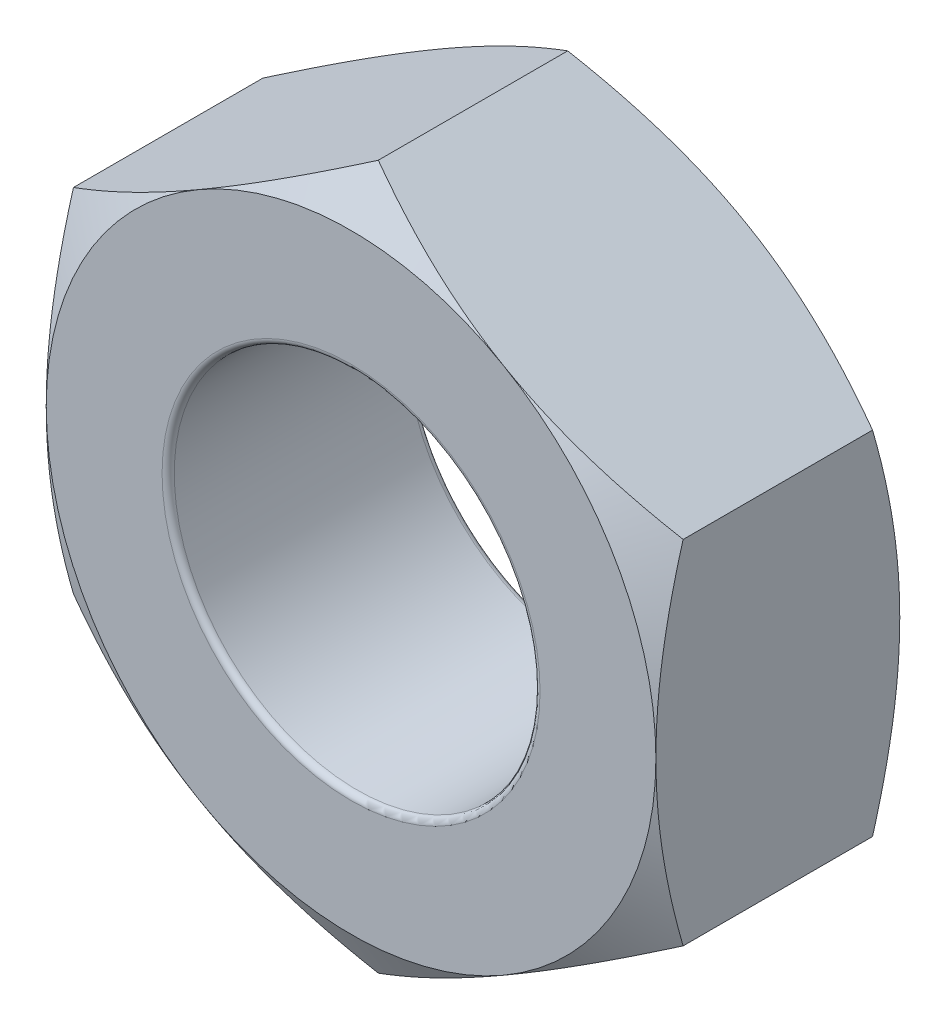
from build123d import *

# Parameters (mm, degrees)
SKETCH1_R           = 1.5
BOSS_EXTRUDE1_DEPTH = 2
SKETCH2_OUTSIDE_W   = 15.508
SKETCH2_OUTSIDE_H   = 16.282
SKETCH2_OUTSIDE_R   = 2.5
CUT_EXTRUDE1_DEPTH  = 2
CUT_EXTRUDE1_TAPER  = 60
SKETCH3_OUTSIDE_W   = 15.508
SKETCH3_OUTSIDE_H   = 16.282
SKETCH3_OUTSIDE_R   = 2.5
CUT_EXTRUDE2_DEPTH  = 2
CUT_EXTRUDE2_TAPER  = 60
FILLET1_R           = 0.05


with BuildPart() as part:
    # Sketch1 → Boss-Extrude1 (new body)
    with BuildSketch(Plane.XY):
        Polygon((0, -2.886751346), (2.5, -1.443375673), (2.5, 1.443375673), (0, 2.886751346), (-2.5, 1.443375673), (-2.5, -1.443375673), align=None)
        Circle(SKETCH1_R, mode=Mode.SUBTRACT)
    extrude(amount=BOSS_EXTRUDE1_DEPTH)

    # Sketch2 outside → Cut-Extrude1 (cut)
    with BuildSketch(Plane.XY.offset(2)):
        Rectangle(SKETCH2_OUTSIDE_W, SKETCH2_OUTSIDE_H)
        Circle(SKETCH2_OUTSIDE_R, mode=Mode.SUBTRACT)
    extrude(amount=-CUT_EXTRUDE1_DEPTH, taper=CUT_EXTRUDE1_TAPER, mode=Mode.SUBTRACT)

    # Sketch3 outside → Cut-Extrude2 (cut)
    with BuildSketch(Plane(origin=(0, 0, 0), x_dir=(-1, 0, 0), z_dir=(0, 0, -1))):
        Rectangle(SKETCH3_OUTSIDE_W, SKETCH3_OUTSIDE_H)
        Circle(SKETCH3_OUTSIDE_R, mode=Mode.SUBTRACT)
    extrude(amount=-CUT_EXTRUDE2_DEPTH, taper=CUT_EXTRUDE2_TAPER, mode=Mode.SUBTRACT)

    # Fillet1
    fillet1_edges = [part.edges().sort_by_distance(p)[0] for p in [
        (-1.5, 0, 0),
        (-1.5, 0, 2),
    ]]
    fillet(fillet1_edges, radius=FILLET1_R)


solid = part.part
